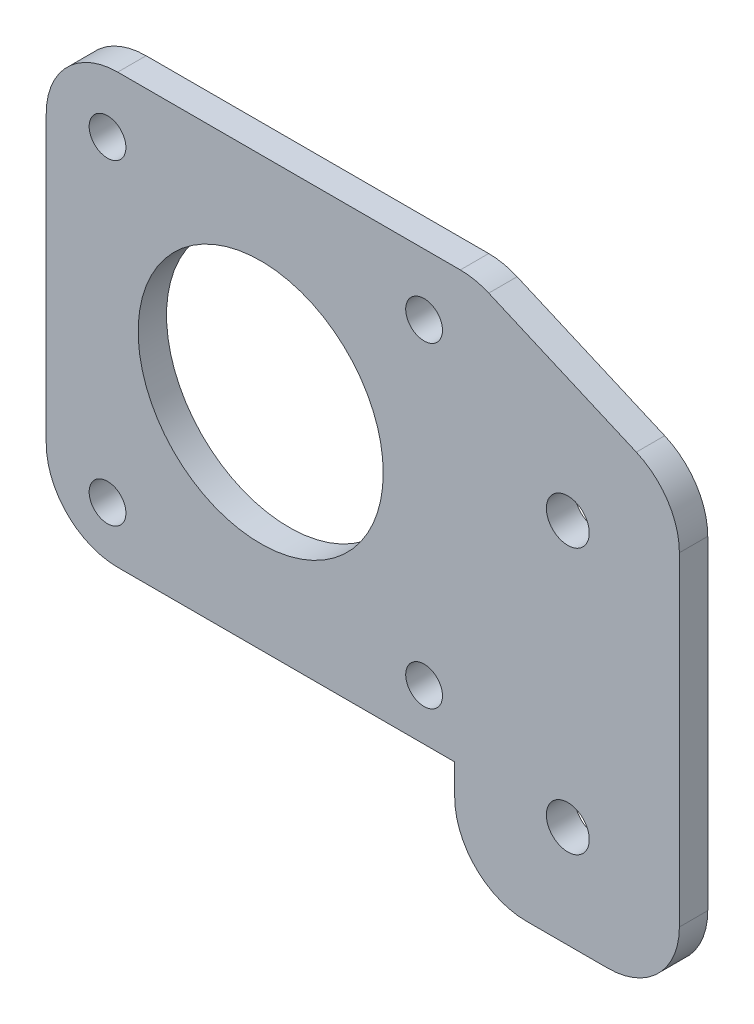
from build123d import *

# Parameters (mm, degrees)
SKETCH1_W           = 62
SKETCH1_H           = 52
BOSS_EXTRUDE1_DEPTH = 2.778125
CUT_EXTRUDE1_DEPTH  = 10
SKETCH2_W           = 40
SKETCH2_H           = 10
CUT_EXTRUDE2_DEPTH  = 10
FILLET1_R           = 7
FILLET2_R           = 7
SKETCH4_R           = 2.1
SKETCH4_R_2         = 1.8
SKETCH4_R_3         = 12
CUT_EXTRUDE3_DEPTH  = 10


with BuildPart() as part:
    # Sketch1 → Boss-Extrude1 (new body)
    with BuildSketch(Plane.XY):
        with Locations((-31, 4.465517241)):
            Rectangle(SKETCH1_W, SKETCH1_H)
    extrude(amount=BOSS_EXTRUDE1_DEPTH)

    # Sketch3 → Cut-Extrude1 (cut)
    with BuildSketch(Plane.XY.offset(2.778125)):
        Polygon((-20, 30.465517241), (0, 21.802451622), (0, 30.465517241), align=None)
    extrude(amount=-CUT_EXTRUDE1_DEPTH, mode=Mode.SUBTRACT)

    # Sketch2 → Cut-Extrude2 (cut)
    with BuildSketch(Plane.XY.offset(2.778125)):
        with Locations((-42, -16.534482759)):
            Rectangle(SKETCH2_W, SKETCH2_H)
    extrude(amount=-CUT_EXTRUDE2_DEPTH, mode=Mode.SUBTRACT)

    # Fillet1
    fillet1_edges = [part.edges().sort_by_distance(p)[0] for p in [
        (-62, -11.534482759, 1.3890625),
        (-22, -21.534482759, 1.3890625),
        (-62, 30.465517241, 1.3890625),
        (0, -21.534482759, 1.3890625),
    ]]
    fillet(fillet1_edges, radius=FILLET1_R)

    # Fillet2
    fillet2_edges = [part.edges().sort_by_distance(p)[0] for p in [
        (0, 21.802451622, 1.3890625),
        (-20, 30.465517241, 1.3890625),
    ]]
    fillet(fillet2_edges, radius=FILLET2_R)

    # Sketch4 → Cut-Extrude3 (cut)
    with BuildSketch(Plane.XY.offset(2.778125)):
        with Locations((-10.925971148, -11.534482759)):
            Circle(SKETCH4_R)
        with Locations((-10.925971148, 14.465517241)):
            Circle(SKETCH4_R)
        with Locations((-56, -6.534482759)):
            Circle(SKETCH4_R_2)
        with Locations((-56, 24.465517241)):
            Circle(SKETCH4_R_2)
        with Locations((-25, 24.465517241)):
            Circle(SKETCH4_R_2)
        with Locations((-25, -6.534482759)):
            Circle(SKETCH4_R_2)
        with Locations((-41, 9.468169555)):
            Circle(SKETCH4_R_3)
    extrude(amount=-CUT_EXTRUDE3_DEPTH, mode=Mode.SUBTRACT)


solid = part.part
